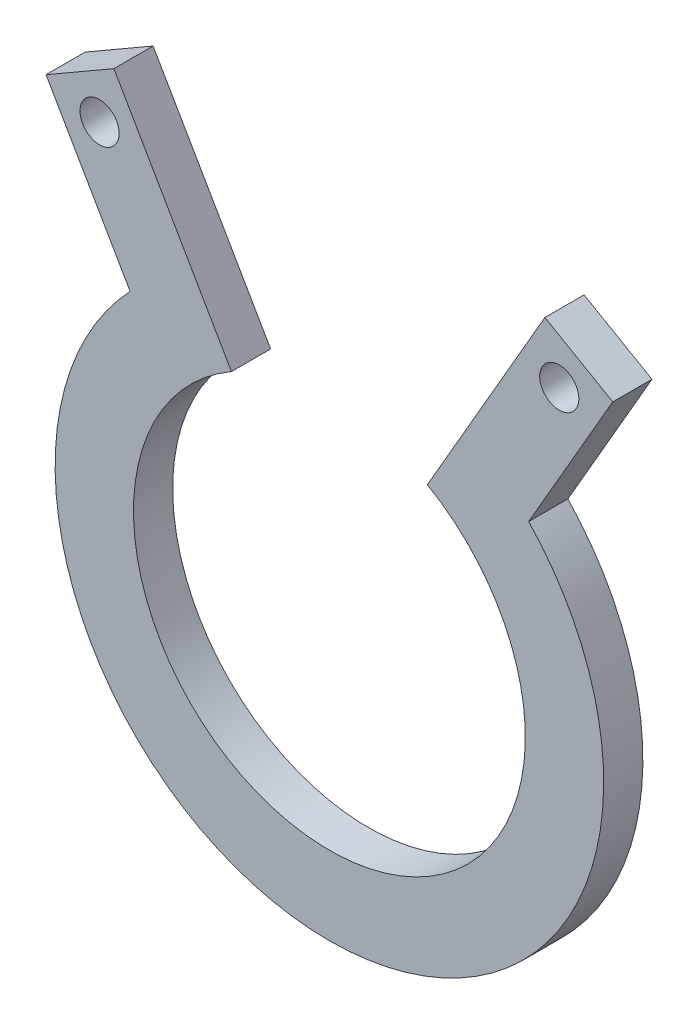
from build123d import *

# Parameters (mm, degrees)
SKETCH2_R           = 22.225
SKETCH2_R_2         = 19.05
SKETCH2_R_3         = 15.875
BOSS_EXTRUDE1_DEPTH = 3.175
SKETCH3_R           = 1.5875
BOSS_EXTRUDE2_DEPTH = 3.175
CUT_EXTRUDE1_DEPTH  = 3.175


with BuildPart() as part:
    # Sketch2 → Boss-Extrude1 (new body)
    with BuildSketch(Plane.XY):
        Circle(SKETCH2_R)
        Circle(SKETCH2_R_2, mode=Mode.SUBTRACT)
        Circle(SKETCH2_R_2)
        Circle(SKETCH2_R_3, mode=Mode.SUBTRACT)
    extrude(amount=BOSS_EXTRUDE1_DEPTH)

    # Sketch3 → Boss-Extrude2 (add)
    with BuildSketch(Plane.XY.offset(3.175)):
        with BuildLine():
            ThreePointArc((-16.148535057, 15.270083186), (-13.77482484, 17.441468562), (-11.1125, 19.247414599))
            Line((-11.1125, 19.247414599), (-17.4625, 30.245937227))
            Line((-17.4625, 30.245937227), (-22.961761314, 27.070937227))
            Line((-22.961761314, 27.070937227), (-16.611761314, 16.072414599))
            Line((-16.611761314, 16.072414599), (-16.148535057, 15.270083186))
        make_face()
        with Locations((-18.624630657, 25.90880657)):
            Circle(SKETCH3_R, mode=Mode.SUBTRACT)
        with BuildLine():
            Line((17.4625, 30.245937227), (11.1125, 19.247414599))
            ThreePointArc((11.1125, 19.247414599), (13.77482484, 17.441468562), (16.148535057, 15.270083186))
            Line((16.148535057, 15.270083186), (16.611761314, 16.072414599))
            Line((16.611761314, 16.072414599), (22.961761314, 27.070937227))
            Line((22.961761314, 27.070937227), (17.4625, 30.245937227))
        make_face()
        with Locations((18.624630657, 25.90880657)):
            Circle(SKETCH3_R, mode=Mode.SUBTRACT)
    extrude(amount=-BOSS_EXTRUDE2_DEPTH)

    # Sketch5 → Cut-Extrude1 (cut)
    with BuildSketch(Plane.XY.offset(3.175)):
        with BuildLine():
            Line((-11.1125, 19.247414599), (0, 0))
            Line((0, 0), (11.1125, 19.247414599))
            ThreePointArc((11.1125, 19.247414599), (0, 22.225), (-11.1125, 19.247414599))
        make_face()
    extrude(amount=-CUT_EXTRUDE1_DEPTH, mode=Mode.SUBTRACT)


solid = part.part
